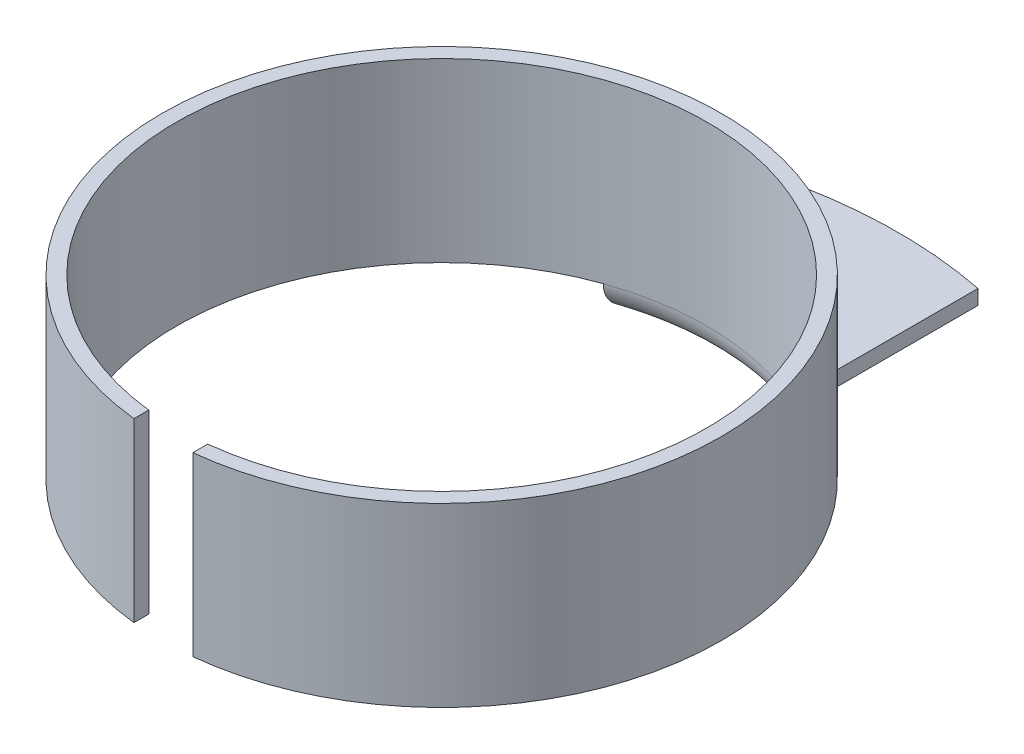
from build123d import *

# Parameters (mm, degrees)
CUT_EXTRUDE_1_DEPTH = 0.5
CUT_EXTRUDE_2_DEPTH = 4.5
FILLET_1_R          = 0.25
FILLET_2_R          = 0.5


with BuildPart() as part:
    # Эскиз1 → Повернуть1 (revolve)
    with BuildSketch(Plane.XY):
        Polygon((4.5, 0), (4.5, 3.5), (4.75, 3.5), (4.75, 0.25), (7.75, 0.25), (7.75, 0), align=None)
    revolve(axis=Axis((0, 0, 0), (0, 1, 0)))

    # Эскиз2 → Вырез-Вытянуть1 (cut)
    with BuildSketch(Plane.XZ):
        with BuildLine():
            Line((-1.5, -7.603453163), (-1.5, -2.4))
            Line((-1.5, -2.4), (1.5, -2.4))
            Line((1.5, -2.4), (1.5, -7.603453163))
            ThreePointArc((1.5, -7.603453163), (0, 7.75), (-1.5, -7.603453163))
        make_face()
    extrude(amount=-CUT_EXTRUDE_1_DEPTH, mode=Mode.SUBTRACT)

    # Эскиз3 → Вырез-Вытянуть2 (cut, through all)
    with BuildSketch(Plane(origin=(0, 3.5, 0), x_dir=(1, 0, 0), z_dir=(0, 1, 0))):
        with BuildLine():
            ThreePointArc((0.5, -4.472135955), (0, -4.5), (-0.5, -4.472135955))
            Line((-0.5, -4.472135955), (-0.5, -4.723610907))
            ThreePointArc((-0.5, -4.723610907), (0, -4.75), (0.5, -4.723610907))
            Line((0.5, -4.723610907), (0.5, -4.472135955))
        make_face()
    extrude(amount=-CUT_EXTRUDE_2_DEPTH, mode=Mode.SUBTRACT)

    # Скругление1
    fillet_1_edges = [part.edges().sort_by_distance(p)[0] for p in [
        (0, 0.25, -4.75),
    ]]
    fillet(fillet_1_edges, radius=FILLET_1_R)

    # Скругление2
    fillet_2_edges = [part.edges().sort_by_distance(p)[0] for p in [
        (0, 0, -4.5),
    ]]
    fillet(fillet_2_edges, radius=FILLET_2_R)


solid = part.part
